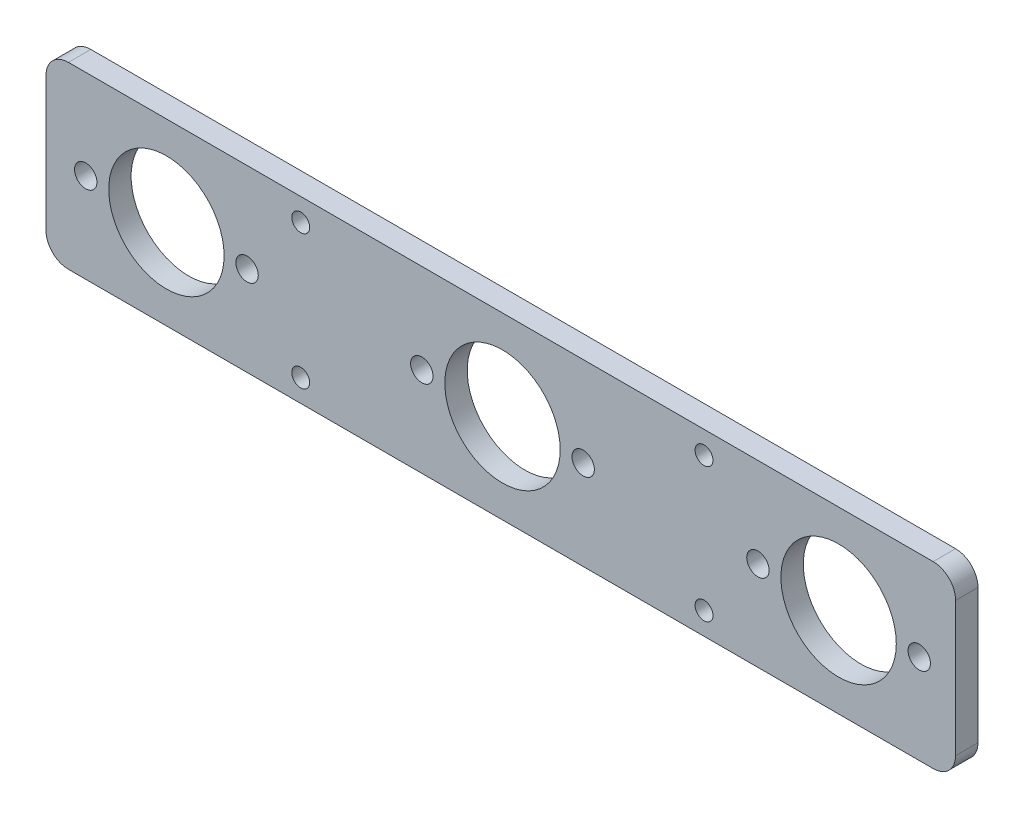
from build123d import *

# Parameters (mm, degrees)
SKETCH_1_R      = 12.875
SKETCH_1_R_2    = 2.5
SKETCH_1_R_3    = 2
EXTRUDE_1_DEPTH = 5


with BuildPart() as part:
    # 草圖1 → 填料-伸長1 (new body)
    with BuildSketch(Plane.XY):
        with BuildLine():
            Line((101.586916073, -15.409026209), (101.586916073, 14.590973791))
            ThreePointArc((101.586916073, 14.590973791), (100.122449979, 18.126507697), (96.586916073, 19.590973791))
            Line((96.586916073, 19.590973791), (-96.393866435, 19.590973791))
            ThreePointArc((-96.393866435, 19.590973791), (-99.929400341, 18.126507697), (-101.393866435, 14.590973791))
            Line((-101.393866435, 14.590973791), (-101.393866435, -15.409026209))
            ThreePointArc((-101.393866435, -15.409026209), (-99.929400341, -18.944560115), (-96.393866435, -20.409026209))
            Line((-96.393866435, -20.409026209), (96.586916073, -20.409026209))
            ThreePointArc((96.586916073, -20.409026209), (100.122449979, -18.944560115), (101.586916073, -15.409026209))
        make_face()
        with Locations((-74.523676725, -0.409026209)):
            Circle(SKETCH_1_R, mode=Mode.SUBTRACT)
        with Locations((-56.523676725, -0.409026209)):
            Circle(SKETCH_1_R_2, mode=Mode.SUBTRACT)
        with Locations((-92.523676725, -0.409026209)):
            Circle(SKETCH_1_R_2, mode=Mode.SUBTRACT)
        with Locations((-17.523676725, -0.409026209)):
            Circle(SKETCH_1_R_2, mode=Mode.SUBTRACT)
        with Locations((0.476323275, -0.409026209)):
            Circle(SKETCH_1_R, mode=Mode.SUBTRACT)
        with Locations((18.476323275, -0.409026209)):
            Circle(SKETCH_1_R_2, mode=Mode.SUBTRACT)
        with Locations((57.476323275, -0.409026209)):
            Circle(SKETCH_1_R_2, mode=Mode.SUBTRACT)
        with Locations((75.476323275, -0.409026209)):
            Circle(SKETCH_1_R, mode=Mode.SUBTRACT)
        with Locations((93.476323275, -0.409026209)):
            Circle(SKETCH_1_R_2, mode=Mode.SUBTRACT)
        with Locations((-44.555800908, 14.590973791)):
            Circle(SKETCH_1_R_3, mode=Mode.SUBTRACT)
        with Locations((-44.555800908, -15.409026209)):
            Circle(SKETCH_1_R_3, mode=Mode.SUBTRACT)
        with Locations((45.450630342, 14.590973791)):
            Circle(SKETCH_1_R_3, mode=Mode.SUBTRACT)
        with Locations((45.450630342, -15.409026209)):
            Circle(SKETCH_1_R_3, mode=Mode.SUBTRACT)
    extrude(amount=EXTRUDE_1_DEPTH)


solid = part.part
